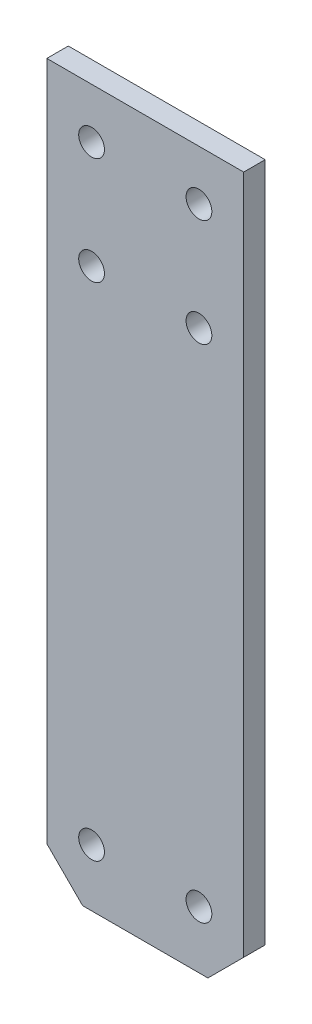
from build123d import *

# Parameters (mm, degrees)
SKETCH1_W                = 27.5
SKETCH1_H                = 100
BOSS_EXTRUDE1_DEPTH      = 3
M3_CLEARANCE_HOLE1_D     = 3.6
M3_CLEARANCE_HOLE1_DEPTH = 30
M3_CLEARANCE_HOLE1_TIP   = 1.081549114
CHAMFER1_SIZE            = 5


with BuildPart() as part:
    # Sketch1 → Boss-Extrude1 (new body)
    with BuildSketch(Plane.XY):
        Rectangle(SKETCH1_W, SKETCH1_H)
    extrude(amount=BOSS_EXTRUDE1_DEPTH)

    # M3 Clearance Hole1
    with Locations(Plane.XY.offset(3)):
        with Locations((-7.5, 43), (7.5, 43), (7.5, 28), (-7.5, 28), (-7.5, -42), (7.5, -42)):
            Hole(M3_CLEARANCE_HOLE1_D / 2, depth=M3_CLEARANCE_HOLE1_DEPTH)
            with Locations((0, 0, -(M3_CLEARANCE_HOLE1_DEPTH + M3_CLEARANCE_HOLE1_TIP / 2))):  # 118° drill point
                Cone(0, M3_CLEARANCE_HOLE1_D / 2, M3_CLEARANCE_HOLE1_TIP, mode=Mode.SUBTRACT)

    # Chamfer1
    chamfer1_edges = [part.edges().sort_by_distance(p)[0] for p in [
        (13.75, -50, 1.5),
        (-13.75, -50, 1.5),
    ]]
    chamfer(chamfer1_edges, length=CHAMFER1_SIZE)


solid = part.part
